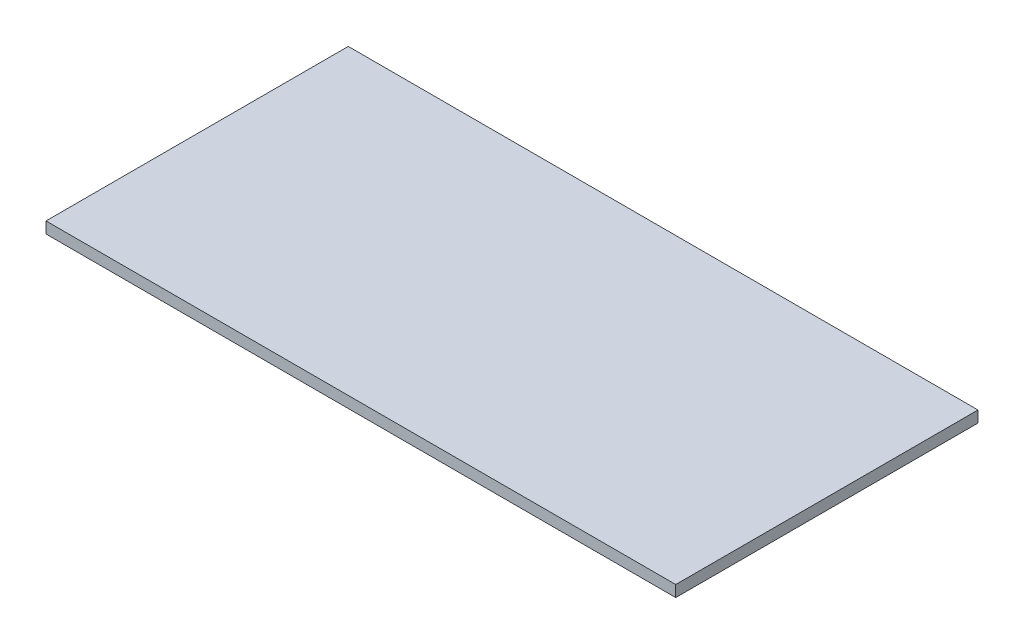
from build123d import *

# Parameters (mm, degrees)
SKETCH_1_W      = 100
SKETCH_1_H      = 48
EXTRUDE_1_DEPTH = 1.8


with BuildPart() as part:
    # 草图1 → 凸台-拉伸1 (new body)
    with BuildSketch(Plane(origin=(0, 0, 0), x_dir=(1, 0, 0), z_dir=(0, 1, 0))):
        with Locations((50, 24)):
            Rectangle(SKETCH_1_W, SKETCH_1_H)
    extrude(amount=EXTRUDE_1_DEPTH)


solid = part.part
